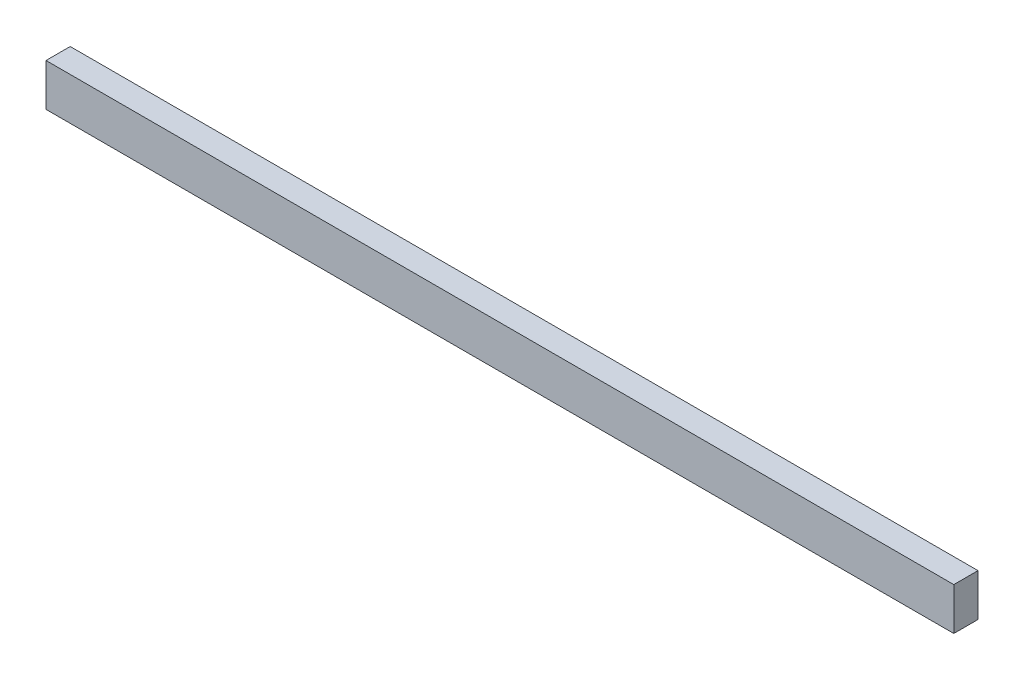
from build123d import *

# Parameters (mm, degrees)
SKETCH_1_W      = 1500
SKETCH_1_H      = 70
EXTRUDE_1_DEPTH = 40


with BuildPart() as part:
    # Эскиз1 → Бобышка-Вытянуть1 (new body)
    with BuildSketch(Plane.XY):
        Rectangle(SKETCH_1_W, SKETCH_1_H)
    extrude(amount=EXTRUDE_1_DEPTH)


solid = part.part
